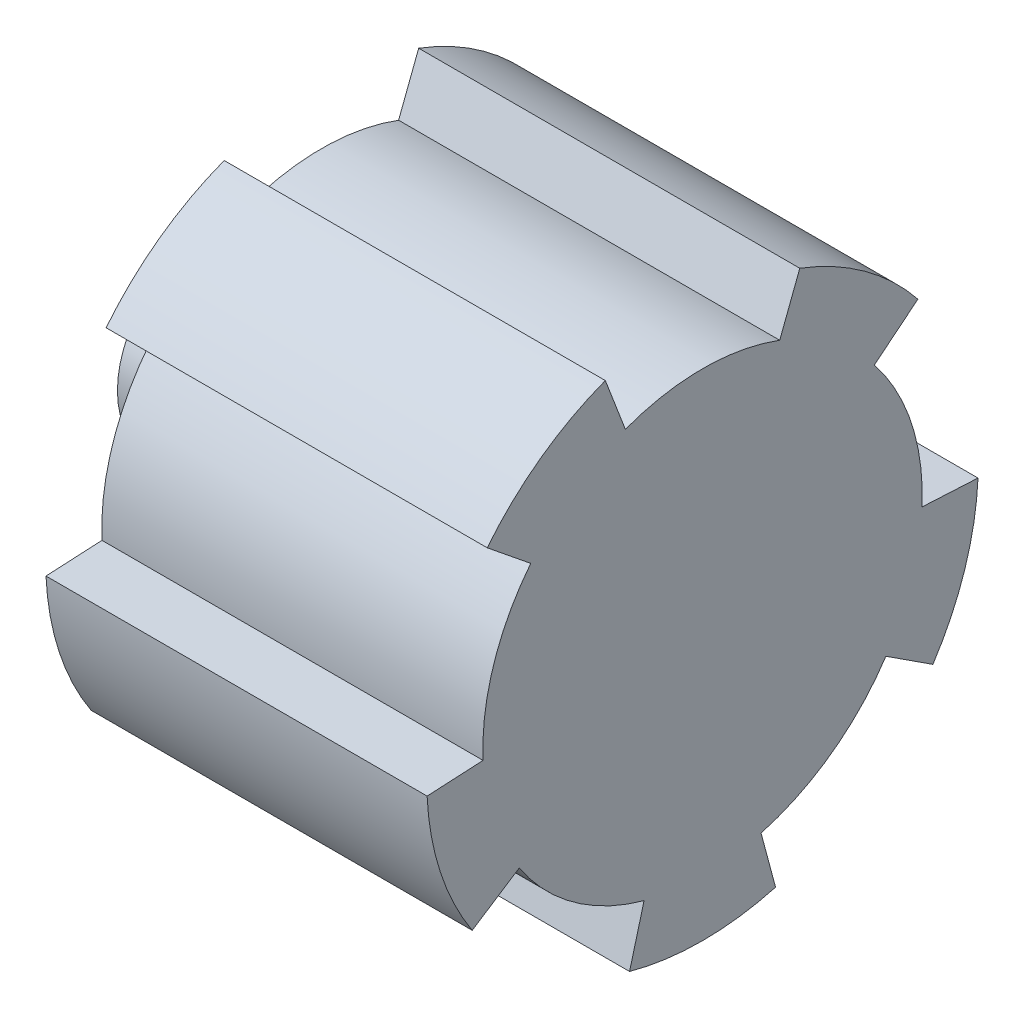
from build123d import *

# Parameters (mm, degrees)
KEYEDBODY_DEPTH  = 17
SKETCH2_R        = 4.1
SMALLSHAFT_DEPTH = 5


with BuildPart() as part:
    # Sketch1 → KeyedBody (new body)
    with BuildSketch(Plane.ZY.offset(18)):
        with BuildLine():
            Line((-3.441775952, 9.17573857), (-4.337445486, 11.509037479))
            ThreePointArc((-4.337445486, 11.509037479), (-7.229313618, 9.950296561), (-9.605400723, 7.681643964))
            Line((-9.605400723, 7.681643964), (-7.663078698, 6.108782601))
            ThreePointArc((-7.663078698, 6.108782601), (-9.32035386, 3.028366545), (-9.790213218, -0.437864293))
            Line((-9.790213218, -0.437864293), (-12.286089458, -0.568667624))
            ThreePointArc((-12.286089458, -0.568667624), (-11.697275149, -3.800675088), (-10.273909609, -6.76152042))
            Line((-10.273909609, -6.76152042), (-8.177819046, -5.400303292))
            ThreePointArc((-8.177819046, -5.400303292), (-5.760295472, -7.928366545), (-2.608908574, -9.446353585))
            Line((-2.608908574, -9.446353585), (-3.255775388, -11.860493399))
            ThreePointArc((-3.255775388, -11.860493399), (0, -12.299242946), (3.255775388, -11.860493399))
            Line((3.255775388, -11.860493399), (2.608908574, -9.446353585))
            ThreePointArc((2.608908574, -9.446353585), (5.760295472, -7.928366545), (8.177819046, -5.400303292))
            Line((8.177819046, -5.400303292), (10.273909609, -6.76152042))
            ThreePointArc((10.273909609, -6.76152042), (11.697275149, -3.800675088), (12.286089458, -0.568667624))
            Line((12.286089458, -0.568667624), (9.790213218, -0.437864293))
            ThreePointArc((9.790213218, -0.437864293), (9.32035386, 3.028366545), (7.663078698, 6.108782601))
            Line((7.663078698, 6.108782601), (9.605400723, 7.681643964))
            ThreePointArc((9.605400723, 7.681643964), (7.229313618, 9.950296561), (4.337445486, 11.509037479))
            Line((4.337445486, 11.509037479), (3.441775952, 9.17573857))
            ThreePointArc((3.441775952, 9.17573857), (0, 9.8), (-3.441775952, 9.17573857))
        make_face()
    extrude(amount=KEYEDBODY_DEPTH)

    # Sketch2 → SmallShaft (add)
    with BuildSketch(Plane.ZY.offset(35)):
        Circle(SKETCH2_R)
    extrude(amount=SMALLSHAFT_DEPTH)


solid = part.part
